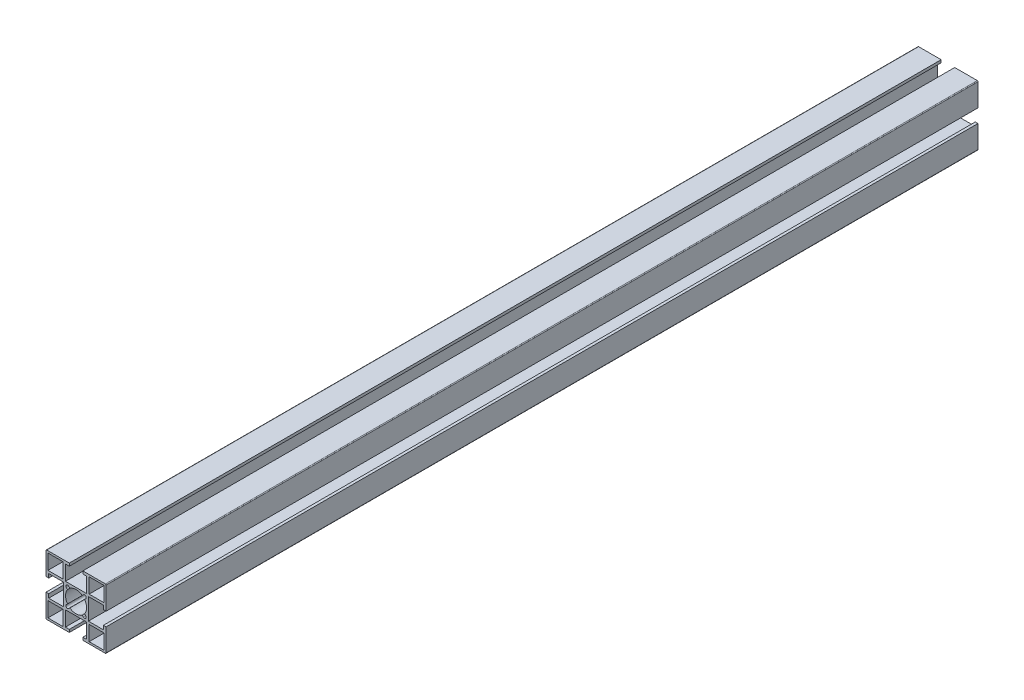
from build123d import *

# Parameters (mm, degrees)
SKETCH1_W                 = 10
SKETCH1_H                 = 10
F_40_X_40A_X_R0_5_1_DEPTH = 580


with BuildPart() as part:
    # Sketch1 → 铝型材 40 X 40A X R0.5(1) (new body)
    with BuildSketch(Plane.YX):
        with BuildLine():
            Line((-19.5, 20), (-4.5, 20))
            Line((-4.5, 20), (-4.5, 18.2))
            Line((-4.5, 18.2), (-7.1, 18.2))
            Line((-7.1, 18.2), (-7.1, 8.2))
            Line((-7.1, 8.2), (7.1, 8.2))
            Line((7.1, 8.2), (7.1, 18.2))
            Line((7.1, 18.2), (4.5, 18.2))
            Line((4.5, 18.2), (4.5, 20))
            Line((4.5, 20), (19.5, 20))
            ThreePointArc((19.5, 20), (19.853553391, 19.853553391), (20, 19.5))
            Line((20, 19.5), (20, 4.5))
            Line((20, 4.5), (18.2, 4.5))
            Line((18.2, 4.5), (18.2, 7.1))
            Line((18.2, 7.1), (8.2, 7.1))
            Line((8.2, 7.1), (8.2, -7.1))
            Line((8.2, -7.1), (18.2, -7.1))
            Line((18.2, -7.1), (18.2, -4.5))
            Line((18.2, -4.5), (20, -4.5))
            Line((20, -4.5), (20, -19.5))
            ThreePointArc((20, -19.5), (19.853553391, -19.853553391), (19.5, -20))
            Line((19.5, -20), (4.5, -20))
            Line((4.5, -20), (4.5, -18.2))
            Line((4.5, -18.2), (7.1, -18.2))
            Line((7.1, -18.2), (7.1, -8.2))
            Line((7.1, -8.2), (-7.1, -8.2))
            Line((-7.1, -8.2), (-7.1, -18.2))
            Line((-7.1, -18.2), (-4.5, -18.2))
            Line((-4.5, -18.2), (-4.5, -20))
            Line((-4.5, -20), (-19.5, -20))
            ThreePointArc((-19.5, -20), (-19.853553391, -19.853553391), (-20, -19.5))
            Line((-20, -19.5), (-20, -4.5))
            Line((-20, -4.5), (-18.2, -4.5))
            Line((-18.2, -4.5), (-18.2, -7.1))
            Line((-18.2, -7.1), (-8.2, -7.1))
            Line((-8.2, -7.1), (-8.2, 7.1))
            Line((-8.2, 7.1), (-18.2, 7.1))
            Line((-18.2, 7.1), (-18.2, 4.5))
            Line((-18.2, 4.5), (-20, 4.5))
            Line((-20, 4.5), (-20, 19.5))
            ThreePointArc((-20, 19.5), (-19.853553391, 19.853553391), (-19.5, 20))
        make_face()
        with BuildLine():
            Line((-4.87903679, 6.434671709), (-4.110433762, 5.66606868))
            ThreePointArc((-4.110433762, 5.66606868), (0, 7), (4.110433762, 5.66606868))
            Line((4.110433762, 5.66606868), (4.87903679, 6.434671709))
            ThreePointArc((4.87903679, 6.434671709), (6.434671709, 6.434671709), (6.434671709, 4.87903679))
            Line((6.434671709, 4.87903679), (5.66606868, 4.110433762))
            ThreePointArc((5.66606868, 4.110433762), (7, 0), (5.66606868, -4.110433762))
            Line((5.66606868, -4.110433762), (6.434671709, -4.87903679))
            ThreePointArc((6.434671709, -4.87903679), (6.434671709, -6.434671709), (4.87903679, -6.434671709))
            Line((4.87903679, -6.434671709), (4.110433762, -5.66606868))
            ThreePointArc((4.110433762, -5.66606868), (0, -7), (-4.110433762, -5.66606868))
            Line((-4.110433762, -5.66606868), (-4.87903679, -6.434671709))
            ThreePointArc((-4.87903679, -6.434671709), (-6.434671709, -6.434671709), (-6.434671709, -4.87903679))
            Line((-6.434671709, -4.87903679), (-5.66606868, -4.110433762))
            ThreePointArc((-5.66606868, -4.110433762), (-7, 0), (-5.66606868, 4.110433762))
            Line((-5.66606868, 4.110433762), (-6.434671709, 4.87903679))
            ThreePointArc((-6.434671709, 4.87903679), (-6.434671709, 6.434671709), (-4.87903679, 6.434671709))
        make_face(mode=Mode.SUBTRACT)
        with Locations((-13.7, 13.7)):
            Rectangle(SKETCH1_W, SKETCH1_H, mode=Mode.SUBTRACT)
        with Locations((13.7, 13.7)):
            Rectangle(SKETCH1_W, SKETCH1_H, mode=Mode.SUBTRACT)
        with Locations((13.7, -13.7)):
            Rectangle(SKETCH1_W, SKETCH1_H, mode=Mode.SUBTRACT)
        with Locations((-13.7, -13.7)):
            Rectangle(SKETCH1_W, SKETCH1_H, mode=Mode.SUBTRACT)
    extrude(amount=F_40_X_40A_X_R0_5_1_DEPTH)


solid = part.part
